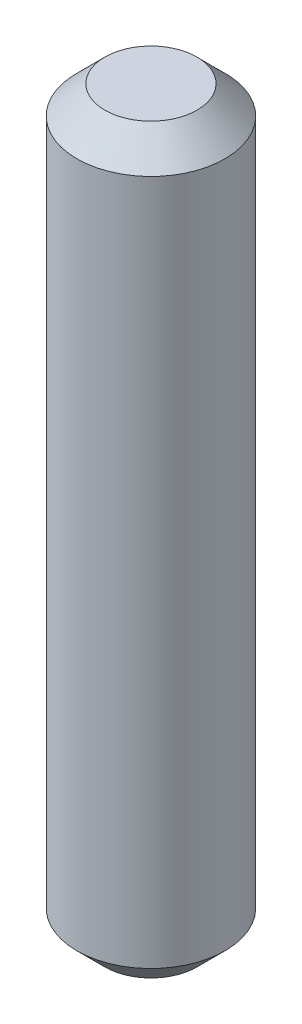
from build123d import *

# Parameters (mm, degrees)
CROQUIS1_R              = 1.585
SALIENTE_EXTRUIR1_DEPTH = 7.935
CHAFL_N1_SIZE           = 0.6


with BuildPart() as part:
    # Croquis1 → Saliente-Extruir1 (new body, symmetric)
    with BuildSketch(Plane(origin=(0, 0, 0), x_dir=(1, 0, 0), z_dir=(0, 1, 0))):
        Circle(CROQUIS1_R)
    extrude(amount=SALIENTE_EXTRUIR1_DEPTH, both=True)

    # Chaflán1
    chafl_n1_edges = [part.edges().sort_by_distance(p)[0] for p in [
        (-1.585, -7.935, 0),
        (-1.585, 7.935, 0),
    ]]
    chamfer(chafl_n1_edges, length=CHAFL_N1_SIZE)


solid = part.part
